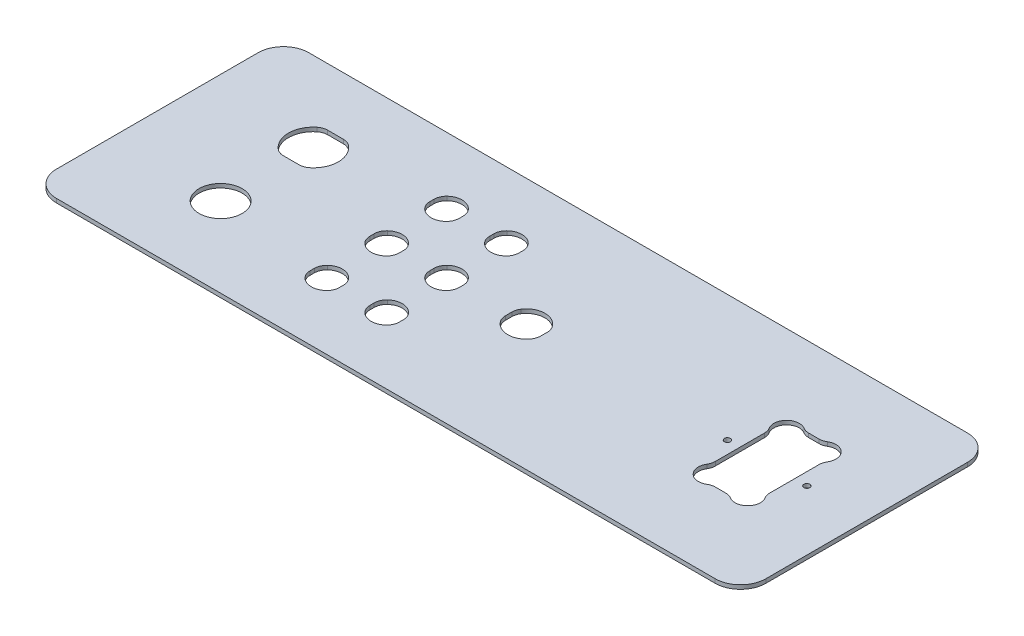
from build123d import *

# Parameters (mm, degrees)
SKETCH1_R           = 10.8
SKETCH1_R_2         = 1.5
BOSS_EXTRUDE1_DEPTH = 2


with BuildPart() as part:
    # Sketch1 → Boss-Extrude1 (new body)
    with BuildSketch(Plane(origin=(0, 0, 0), x_dir=(1, 0, 0), z_dir=(0, 1, 0))):
        with BuildLine():
            Line((-165.1, 63.246), (165.1, 63.246))
            ThreePointArc((165.1, 63.246), (174.080256121, 59.526256121), (177.8, 50.546))
            Line((177.8, 50.546), (177.8, -50.546))
            ThreePointArc((177.8, -50.546), (174.080256121, -59.526256121), (165.1, -63.246))
            Line((165.1, -63.246), (-165.1, -63.246))
            ThreePointArc((-165.1, -63.246), (-174.080256121, -59.526256121), (-177.8, -50.546))
            Line((-177.8, -50.546), (-177.8, 50.546))
            ThreePointArc((-177.8, 50.546), (-174.080256121, 59.526256121), (-165.1, 63.246))
        make_face()
        with Locations((-122.8, -23.246)):
            Circle(SKETCH1_R, mode=Mode.SUBTRACT)
        with Locations((107.99, 0)):
            Circle(SKETCH1_R_2, mode=Mode.SUBTRACT)
        with Locations((147.8, 0)):
            Circle(SKETCH1_R_2, mode=Mode.SUBTRACT)
        with BuildLine():
            Line((-118.893595003, 34.346), (-126.706404997, 34.346))
            ThreePointArc((-126.706404997, 34.346), (-128.848729166, 33.973704171), (-130.739847555, 32.900471545))
            ThreePointArc((-130.739847555, 32.900471545), (-135.3, 23.246), (-130.739847555, 13.591528455))
            ThreePointArc((-130.739847555, 13.591528455), (-128.848729166, 12.518295829), (-126.706404997, 12.146))
            Line((-126.706404997, 12.146), (-118.893595003, 12.146))
            ThreePointArc((-118.893595003, 12.146), (-116.751270834, 12.518295829), (-114.860152445, 13.591528455))
            ThreePointArc((-114.860152445, 13.591528455), (-110.3, 23.246), (-114.860152445, 32.900471545))
            ThreePointArc((-114.860152445, 32.900471545), (-116.751270834, 33.973704171), (-118.893595003, 34.346))
        make_face(mode=Mode.SUBTRACT)
        with BuildLine():
            Line((-70.115, 31.014285463), (-70.115, 28.985714537))
            ThreePointArc((-70.115, 28.985714537), (-69.600932797, 26.482838513), (-68.141964286, 24.385205474))
            ThreePointArc((-68.141964286, 24.385205474), (-62.8, 22.25), (-57.458035714, 24.385205474))
            ThreePointArc((-57.458035714, 24.385205474), (-55.999067203, 26.482838513), (-55.485, 28.985714537))
            Line((-55.485, 28.985714537), (-55.485, 31.014285463))
            ThreePointArc((-55.485, 31.014285463), (-55.999067203, 33.517161487), (-57.458035714, 35.614794526))
            ThreePointArc((-57.458035714, 35.614794526), (-62.8, 37.75), (-68.141964286, 35.614794526))
            ThreePointArc((-68.141964286, 35.614794526), (-69.600932797, 33.517161487), (-70.115, 31.014285463))
        make_face(mode=Mode.SUBTRACT)
        with BuildLine():
            Line((-40.115, 31.014285463), (-40.115, 28.985714537))
            ThreePointArc((-40.115, 28.985714537), (-39.600932797, 26.482838513), (-38.141964286, 24.385205474))
            ThreePointArc((-38.141964286, 24.385205474), (-32.8, 22.25), (-27.458035714, 24.385205474))
            ThreePointArc((-27.458035714, 24.385205474), (-25.999067203, 26.482838513), (-25.485, 28.985714537))
            Line((-25.485, 28.985714537), (-25.485, 31.014285463))
            ThreePointArc((-25.485, 31.014285463), (-25.999067203, 33.517161487), (-27.458035714, 35.614794526))
            ThreePointArc((-27.458035714, 35.614794526), (-32.8, 37.75), (-38.141964286, 35.614794526))
            ThreePointArc((-38.141964286, 35.614794526), (-39.600932797, 33.517161487), (-40.115, 31.014285463))
        make_face(mode=Mode.SUBTRACT)
        with BuildLine():
            Line((-70.115, 1.014285463), (-70.115, -1.014285463))
            ThreePointArc((-70.115, -1.014285463), (-69.600932797, -3.517161487), (-68.141964286, -5.614794526))
            ThreePointArc((-68.141964286, -5.614794526), (-62.8, -7.75), (-57.458035714, -5.614794526))
            ThreePointArc((-57.458035714, -5.614794526), (-55.999067203, -3.517161487), (-55.485, -1.014285463))
            Line((-55.485, -1.014285463), (-55.485, 1.014285463))
            ThreePointArc((-55.485, 1.014285463), (-55.999067203, 3.517161487), (-57.458035714, 5.614794526))
            ThreePointArc((-57.458035714, 5.614794526), (-62.8, 7.75), (-68.141964286, 5.614794526))
            ThreePointArc((-68.141964286, 5.614794526), (-69.600932797, 3.517161487), (-70.115, 1.014285463))
        make_face(mode=Mode.SUBTRACT)
        with BuildLine():
            Line((-70.115, -28.985714537), (-70.115, -31.014285463))
            ThreePointArc((-70.115, -31.014285463), (-69.600932797, -33.517161487), (-68.141964286, -35.614794526))
            ThreePointArc((-68.141964286, -35.614794526), (-62.8, -37.75), (-57.458035714, -35.614794526))
            ThreePointArc((-57.458035714, -35.614794526), (-55.999067203, -33.517161487), (-55.485, -31.014285463))
            Line((-55.485, -31.014285463), (-55.485, -28.985714537))
            ThreePointArc((-55.485, -28.985714537), (-55.999067203, -26.482838513), (-57.458035714, -24.385205474))
            ThreePointArc((-57.458035714, -24.385205474), (-62.8, -22.25), (-68.141964286, -24.385205474))
            ThreePointArc((-68.141964286, -24.385205474), (-69.600932797, -26.482838513), (-70.115, -28.985714537))
        make_face(mode=Mode.SUBTRACT)
        with BuildLine():
            Line((-40.115, -28.985714537), (-40.115, -31.014285463))
            ThreePointArc((-40.115, -31.014285463), (-39.600932797, -33.517161487), (-38.141964286, -35.614794526))
            ThreePointArc((-38.141964286, -35.614794526), (-32.8, -37.75), (-27.458035714, -35.614794526))
            ThreePointArc((-27.458035714, -35.614794526), (-25.999067203, -33.517161487), (-25.485, -31.014285463))
            Line((-25.485, -31.014285463), (-25.485, -28.985714537))
            ThreePointArc((-25.485, -28.985714537), (-25.999067203, -26.482838513), (-27.458035714, -24.385205474))
            ThreePointArc((-27.458035714, -24.385205474), (-32.8, -22.25), (-38.141964286, -24.385205474))
            ThreePointArc((-38.141964286, -24.385205474), (-39.600932797, -26.482838513), (-40.115, -28.985714537))
        make_face(mode=Mode.SUBTRACT)
        with BuildLine():
            Line((-25.485, 1.014285463), (-25.485, -1.014285463))
            ThreePointArc((-25.485, -1.014285463), (-25.999067203, -3.517161487), (-27.458035714, -5.614794526))
            ThreePointArc((-27.458035714, -5.614794526), (-32.8, -7.75), (-38.141964286, -5.614794526))
            ThreePointArc((-38.141964286, -5.614794526), (-39.600932797, -3.517161487), (-40.115, -1.014285463))
            Line((-40.115, -1.014285463), (-40.115, 1.014285463))
            ThreePointArc((-40.115, 1.014285463), (-39.600932797, 3.517161487), (-38.141964286, 5.614794526))
            ThreePointArc((-38.141964286, 5.614794526), (-32.8, 7.75), (-27.458035714, 5.614794526))
            ThreePointArc((-27.458035714, 5.614794526), (-25.999067203, 3.517161487), (-25.485, 1.014285463))
        make_face(mode=Mode.SUBTRACT)
        with BuildLine():
            Line((-1.63, 1.61592079), (-1.63, -1.61592079))
            ThreePointArc((-1.63, -1.61592079), (-1.367126425, -3.424066772), (-0.60027027, -5.08250762))
            ThreePointArc((-0.60027027, -5.08250762), (7.2, -9.31), (15.00027027, -5.08250762))
            ThreePointArc((15.00027027, -5.08250762), (15.767126425, -3.424066772), (16.03, -1.61592079))
            Line((16.03, -1.61592079), (16.03, 1.61592079))
            ThreePointArc((16.03, 1.61592079), (15.767126425, 3.424066772), (15.00027027, 5.08250762))
            ThreePointArc((15.00027027, 5.08250762), (7.2, 9.31), (-0.60027027, 5.08250762))
            ThreePointArc((-0.60027027, 5.08250762), (-1.367126425, 3.424066772), (-1.63, 1.61592079))
        make_face(mode=Mode.SUBTRACT)
        with BuildLine():
            Line((125.321896428, 23.415), (130.468103572, 23.415))
            ThreePointArc((130.468103572, 23.415), (132.18640119, 23.651903134), (133.776487756, 24.34493597))
            ThreePointArc((133.776487756, 24.34493597), (141.575, 23.415), (142.50493597, 15.616487756))
            ThreePointArc((142.50493597, 15.616487756), (141.811903134, 14.02640119), (141.575, 12.308103572))
            Line((141.575, 12.308103572), (141.575, -12.308103572))
            ThreePointArc((141.575, -12.308103572), (141.811903134, -14.02640119), (142.50493597, -15.616487756))
            ThreePointArc((142.50493597, -15.616487756), (141.575, -23.415), (133.776487756, -24.34493597))
            ThreePointArc((133.776487756, -24.34493597), (132.18640119, -23.651903134), (130.468103572, -23.415))
            Line((130.468103572, -23.415), (125.321896428, -23.415))
            ThreePointArc((125.321896428, -23.415), (123.60359881, -23.651903134), (122.013512244, -24.34493597))
            ThreePointArc((122.013512244, -24.34493597), (114.215, -23.415), (113.28506403, -15.616487756))
            ThreePointArc((113.28506403, -15.616487756), (113.978096866, -14.02640119), (114.215, -12.308103572))
            Line((114.215, -12.308103572), (114.215, 12.308103572))
            ThreePointArc((114.215, 12.308103572), (113.978096866, 14.02640119), (113.28506403, 15.616487756))
            ThreePointArc((113.28506403, 15.616487756), (114.215, 23.415), (122.013512244, 24.34493597))
            ThreePointArc((122.013512244, 24.34493597), (123.60359881, 23.651903134), (125.321896428, 23.415))
        make_face(mode=Mode.SUBTRACT)
    extrude(amount=BOSS_EXTRUDE1_DEPTH)


solid = part.part
